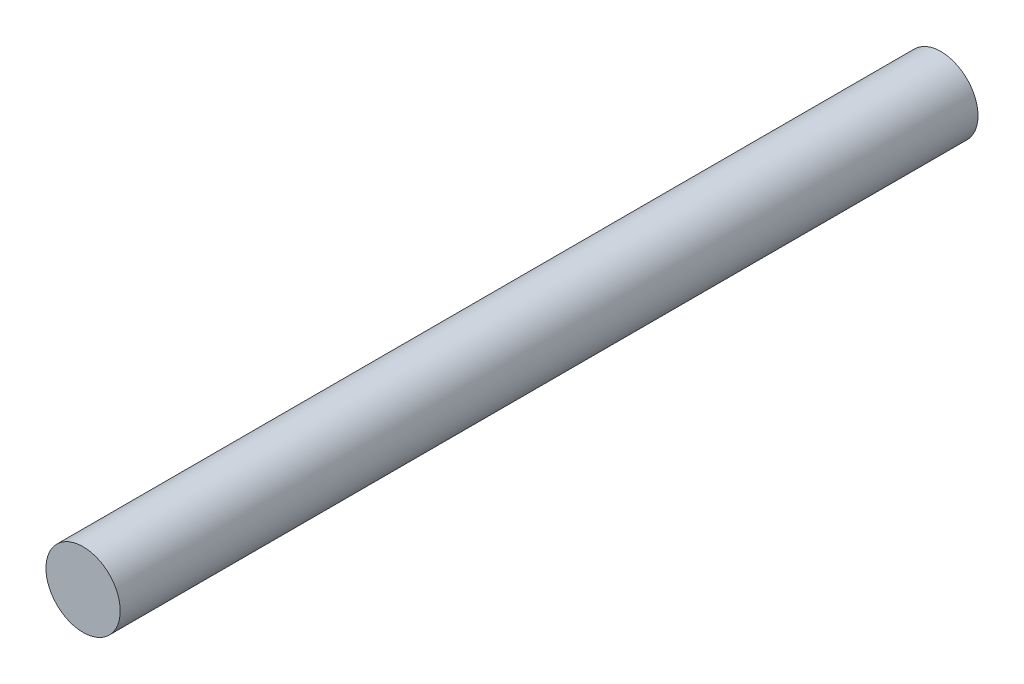
from build123d import *

# Parameters (mm, degrees)
SKETCH1_R           = 5.5
BOSS_EXTRUDE1_DEPTH = 63.5


with BuildPart() as part:
    # Sketch1 → Boss-Extrude1 (new body, symmetric)
    with BuildSketch(Plane.XY):
        Circle(SKETCH1_R)
    extrude(amount=BOSS_EXTRUDE1_DEPTH, both=True)


solid = part.part
